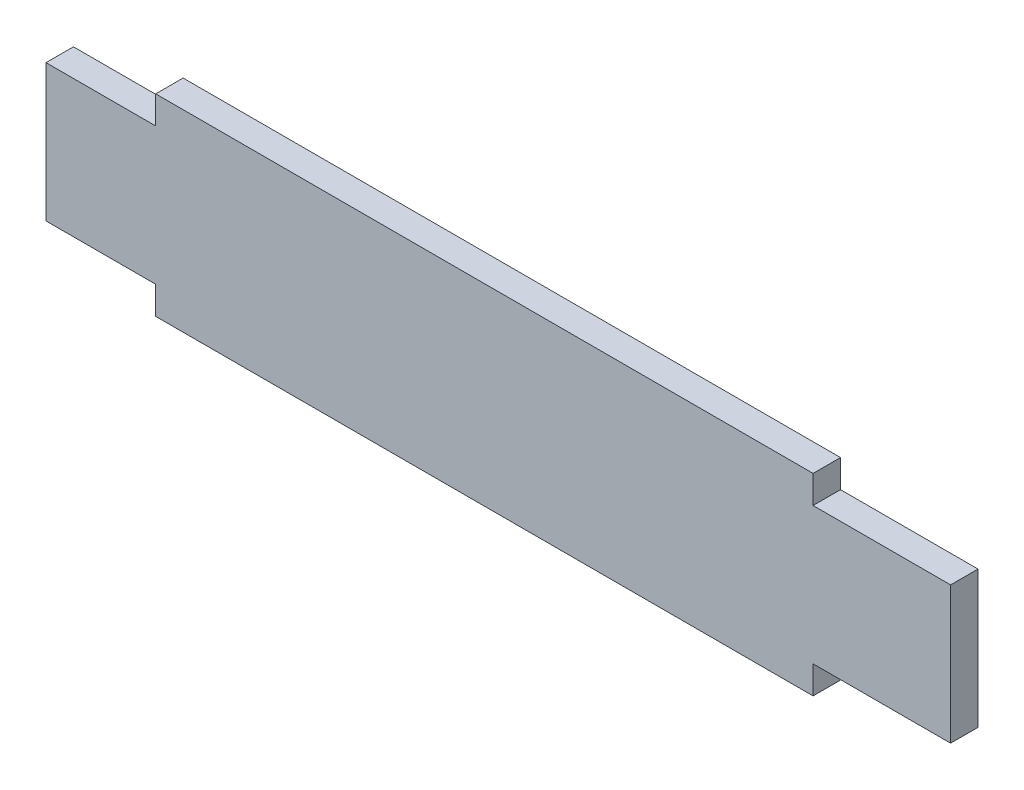
from build123d import *

# Parameters (mm, degrees)
SKETCH_1_W      = 164.93
SKETCH_1_H      = 25
SKETCH_1_W_2    = 119.86
SKETCH_1_H_2    = 5.07
EXTRUDE_1_DEPTH = 5


with BuildPart() as part:
    # ｽｹｯﾁ1 → ﾎﾞｽ - 押し出し1 (new body)
    with BuildSketch(Plane.XY):
        with Locations((82.465, 12.5)):
            Rectangle(SKETCH_1_W, SKETCH_1_H)
        with Locations((79.93, 27.535)):
            Rectangle(SKETCH_1_W_2, SKETCH_1_H_2)
        with Locations((79.93, -2.535)):
            Rectangle(SKETCH_1_W_2, SKETCH_1_H_2)
    extrude(amount=EXTRUDE_1_DEPTH)


solid = part.part
